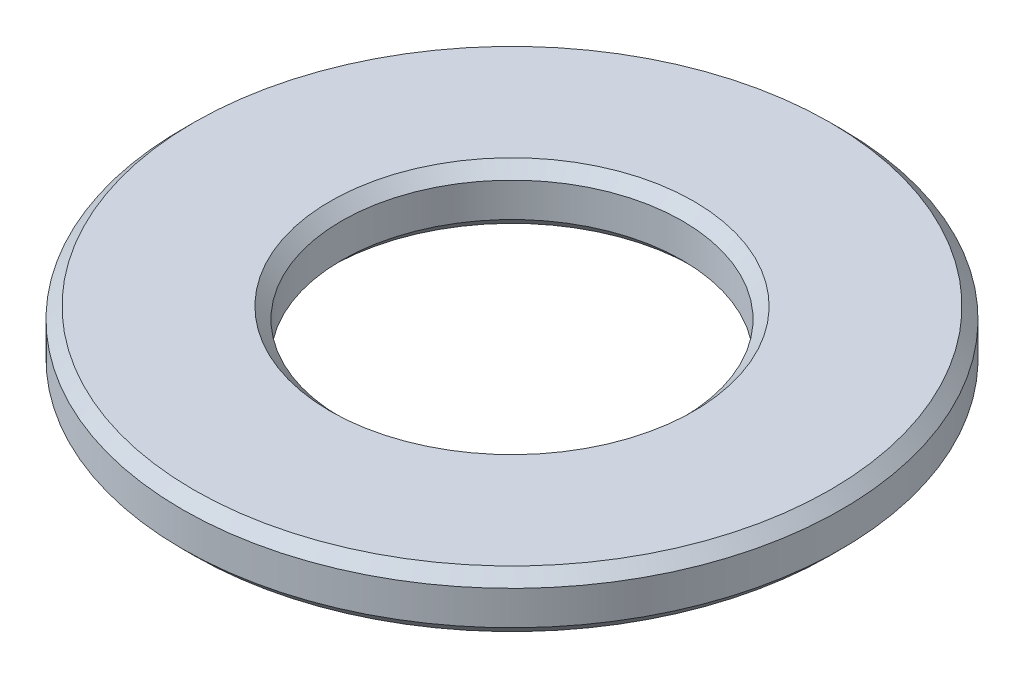
from build123d import *

# Parameters (mm, degrees)
SKIZZE1_R                       = 2.9
SKIZZE1_R_2                     = 1.5
AUFSATZ_LINEAR_AUSTRAGEN1_DEPTH = 0.5
FASE1_SIZE                      = 0.1


with BuildPart() as part:
    # Skizze1 → Aufsatz-Linear austragen1 (new body)
    with BuildSketch(Plane(origin=(0, 0, 0), x_dir=(1, 0, 0), z_dir=(0, 1, 0))):
        Circle(SKIZZE1_R)
        Circle(SKIZZE1_R_2, mode=Mode.SUBTRACT)
    extrude(amount=AUFSATZ_LINEAR_AUSTRAGEN1_DEPTH)

    # Fase1
    fase1_edges = [part.edges().sort_by_distance(p)[0] for p in [
        (-2.9, 0, 0),
        (-2.9, 0.5, 0),
        (-1.5, 0, 0),
        (-1.5, 0.5, 0),
    ]]
    chamfer(fase1_edges, length=FASE1_SIZE)


solid = part.part
